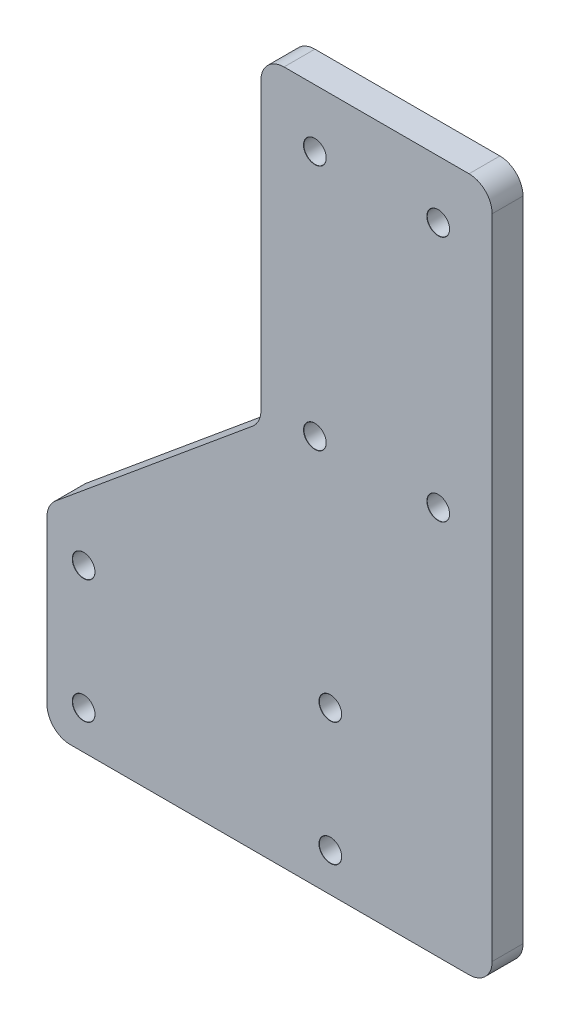
from build123d import *

# Parameters (mm, degrees)
EXTRUDE_1_DEPTH                = 4
HOLE_WIZARD_M2_5_1_D           = 2.9
HOLE_WIZARD_M2_5_1_CSINK_D     = 2.95
HOLE_WIZARD_M2_5_1_CSINK_ANGLE = 90
FILLET_2_R                     = 3


with BuildPart() as part:
    # 草图1 → 凸台-拉伸1 (new body)
    with BuildSketch(Plane.XY):
        Polygon((0, 0), (-41.5, 0), (-41.5, 25.5), (-13.75, 48.5), (-13.75, 90), (16.25, 90), (16.25, 0), align=None)
    extrude(amount=EXTRUDE_1_DEPTH)

    # M2.5 间隙孔1 (through all)
    with Locations(Plane.XY.offset(4)):
        with Locations((9.25, 50.5), (-36.75, 5), (-36.75, 21), (-4.75, 5), (-4.75, 21), (-6.75, 82.5), (9.25, 82.5), (-6.75, 50.5)):
            CounterSinkHole(HOLE_WIZARD_M2_5_1_D / 2, HOLE_WIZARD_M2_5_1_CSINK_D / 2, counter_sink_angle=HOLE_WIZARD_M2_5_1_CSINK_ANGLE)

    # 圆角2
    fillet_2_edges = [part.edges().sort_by_distance(p)[0] for p in [
        (-41.5, 0, 2),
        (-41.5, 25.5, 2),
        (-13.75, 48.5, 2),
        (-13.75, 90, 2),
        (16.25, 90, 2),
        (16.25, 0, 2),
    ]]
    fillet(fillet_2_edges, radius=FILLET_2_R)


solid = part.part
